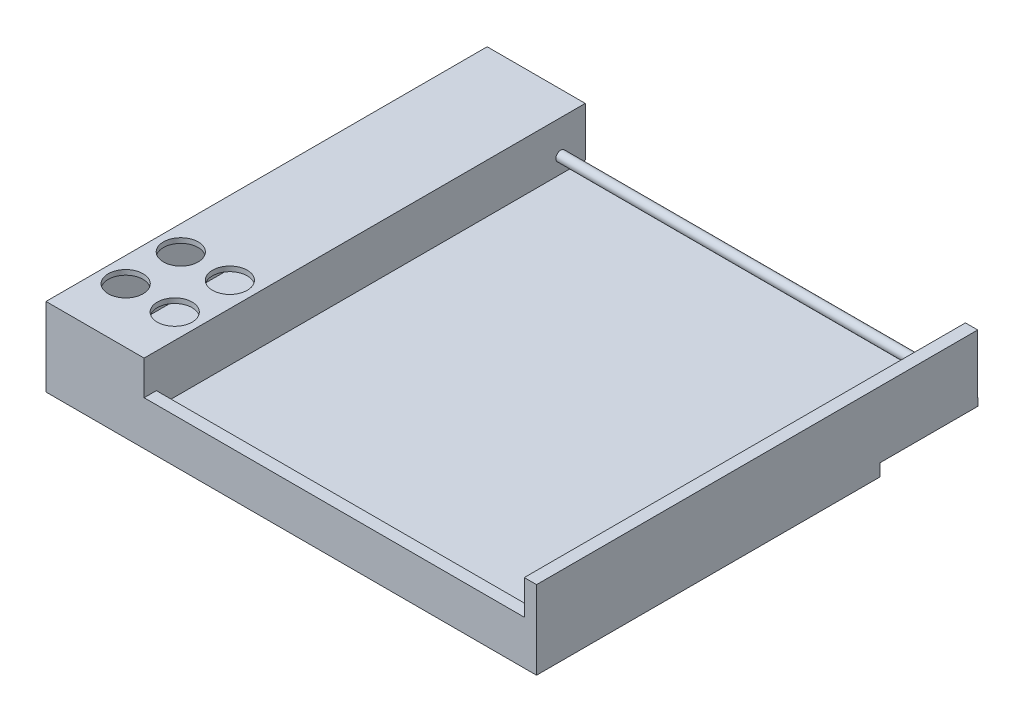
from build123d import *

# Parameters (mm, degrees)
SKETCH1_W           = 200
SKETCH1_H           = 180
BOSS_EXTRUDE1_DEPTH = 3
SKETCH2_W           = 200
SKETCH2_H           = 140
BOSS_EXTRUDE2_DEPTH = 5
SKETCH6_W           = 200
SKETCH6_H           = 179.869705491
BOSS_EXTRUDE3_DEPTH = 24
SKETCH7_W           = 155
SKETCH7_H           = 24
CUT_EXTRUDE1_DEPTH  = 179.869705491
SKETCH8_R           = 2
BOSS_EXTRUDE4_DEPTH = 155
SKETCH9_W           = 155
SKETCH9_H           = 5
BOSS_EXTRUDE5_DEPTH = 10
CUT_EXTRUDE3_DEPTH  = 174.869705491
SKETCH12_R          = 7.1
CUT_EXTRUDE4_DEPTH  = 2


with BuildPart() as part:
    # Sketch1 → Boss-Extrude1 (new body)
    with BuildSketch(Plane(origin=(0, 0, 0), x_dir=(1, 0, 0), z_dir=(0, 1, 0))):
        Rectangle(SKETCH1_W, SKETCH1_H)
    extrude(amount=BOSS_EXTRUDE1_DEPTH)

    # Sketch2 → Boss-Extrude2 (add)
    with BuildSketch(Plane.XZ):
        with Locations((0, 20)):
            Rectangle(SKETCH2_W, SKETCH2_H)
    extrude(amount=BOSS_EXTRUDE2_DEPTH)

    # Sketch6 → Boss-Extrude3 (add)
    with BuildSketch(Plane(origin=(0, 3, 0), x_dir=(1, 0, 0), z_dir=(0, 1, 0))):
        with Locations((0, -0.065147254)):
            Rectangle(SKETCH6_W, SKETCH6_H)
    extrude(amount=BOSS_EXTRUDE3_DEPTH)

    # Sketch7 → Cut-Extrude1 (cut)
    with BuildSketch(Plane(origin=(0, 0, -89.869705491), x_dir=(-1, 0, 0), z_dir=(0, 0, -1))):
        with Locations((-17.5, 15)):
            Rectangle(SKETCH7_W, SKETCH7_H)
    extrude(amount=-CUT_EXTRUDE1_DEPTH, mode=Mode.SUBTRACT)

    # Sketch8 → Boss-Extrude4 (add)
    with BuildSketch(Plane.ZY.offset(-95)):
        with Locations(Location((-79.869705491, 13.5, 0), (0, 0, 180))):
            Circle(SKETCH8_R)
    extrude(amount=BOSS_EXTRUDE4_DEPTH)

    # Sketch9 → Boss-Extrude5 (add)
    with BuildSketch(Plane(origin=(0, 3, 0), x_dir=(1, 0, 0), z_dir=(0, 1, 0))):
        with Locations((17.5, -87.5)):
            Rectangle(SKETCH9_W, SKETCH9_H)
    extrude(amount=BOSS_EXTRUDE5_DEPTH)

    # Sketch11 → Cut-Extrude3 (cut)
    with BuildSketch(Plane(origin=(0, 0, -89.869705491), x_dir=(-1, 0, 0), z_dir=(0, 0, -1))):
        Polygon((60, 3), (98, 3), (98, 25), (62, 25), (62, 7), (60, 7), align=None)
    extrude(amount=-CUT_EXTRUDE3_DEPTH, mode=Mode.SUBTRACT)

    # Sketch12 → Cut-Extrude4 (cut)
    with BuildSketch(Plane(origin=(0, 27, 0), x_dir=(1, 0, 0), z_dir=(0, 1, 0))):
        with Locations(Location((-70, -45.032573627, 0), (0, 0, 270))):
            Circle(SKETCH12_R)
        with Locations(Location((-70, -67.516286814, 0), (0, 0, 270))):
            Circle(SKETCH12_R)
        with Locations(Location((-90, -67.516286814, 0), (0, 0, 180))):
            Circle(SKETCH12_R)
        with Locations(Location((-90, -45.032573627, 0), (0, 0, 180))):
            Circle(SKETCH12_R)
    extrude(amount=-CUT_EXTRUDE4_DEPTH, mode=Mode.SUBTRACT)


solid = part.part
